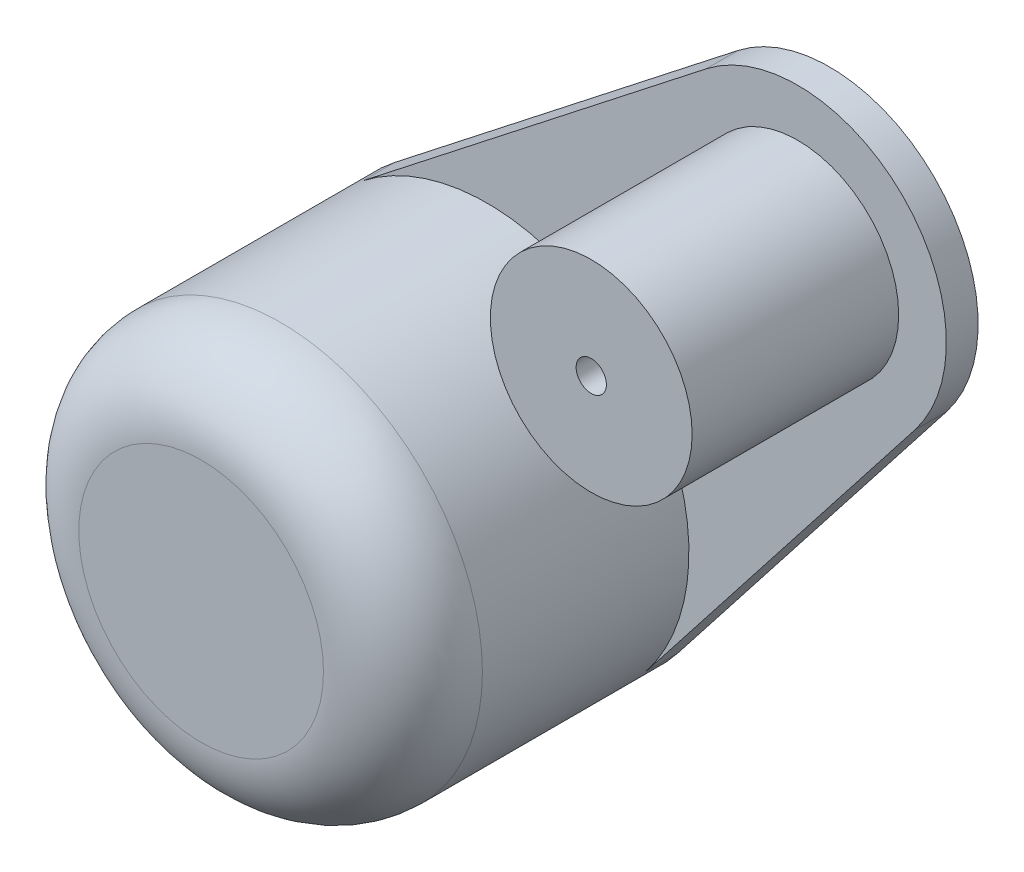
from build123d import *

# Parameters (mm, degrees)
SKETCH1_R           = 12.7
BOSS_EXTRUDE1_DEPTH = 20
FILLET1_R           = 5
CUT_EXTRUDE1_REACH  = 14.7
SKETCH3_R           = 2.4257
CUT_EXTRUDE2_REACH  = 14.7
SKETCH4_R           = 2.4257
BOSS_EXTRUDE2_DEPTH = 2
SKETCH6_R           = 6.35
BOSS_EXTRUDE3_DEPTH = 13
SKETCH8_R           = 0.9525
CUT_EXTRUDE3_DEPTH  = 16.0000001


with BuildPart() as part:
    # Sketch1 → Boss-Extrude1 (new body)
    with BuildSketch(Plane.XY):
        Circle(SKETCH1_R)
    extrude(amount=BOSS_EXTRUDE1_DEPTH)

    # Sketch2 → Cut-Revolve1 (revolve, cut)
    with BuildSketch(Plane(origin=(0, 0, 0), x_dir=(1, 0, 0), z_dir=(0, 1, 0))):
        Polygon((0, 0), (0, -17.175), (3.175, -14), (3.175, 0), align=None)
    revolve(axis=Axis((0, 0, -1), (0, 0, 1)), mode=Mode.SUBTRACT)

    # Fillet1
    fillet1_edges = [part.edges().sort_by_distance(p)[0] for p in [
        (-12.7, 0, 20),
    ]]
    fillet(fillet1_edges, radius=FILLET1_R)

    # Sketch3 → Cut-Extrude1 (cut, up to next)
    with BuildSketch(Plane(origin=(0, 0, 0), x_dir=(1, 0, 0), z_dir=(0, 1, 0)), mode=Mode.PRIVATE) as cut_extrude1_sk1:
        with Locations((0, -6)):
            Circle(SKETCH3_R)
    cut_extrude1_tool1 = extrude(cut_extrude1_sk1.sketch, amount=-CUT_EXTRUDE1_REACH, mode=Mode.PRIVATE) & part.part
    add(cut_extrude1_tool1.solids().sort_by_distance((0, 0, 6))[0], mode=Mode.SUBTRACT)

    # Sketch4 → Cut-Extrude2 (cut, up to next)
    with BuildSketch(Plane(origin=(0, 0, 0), x_dir=(0, 0, -1), z_dir=(1, 0, 0)), mode=Mode.PRIVATE) as cut_extrude2_sk1:
        with Locations((-6, 0)):
            Circle(SKETCH4_R)
    cut_extrude2_tool1 = extrude(cut_extrude2_sk1.sketch, amount=-CUT_EXTRUDE2_REACH, mode=Mode.PRIVATE) & part.part
    add(cut_extrude2_tool1.solids().sort_by_distance((0, 0, 6))[0], mode=Mode.SUBTRACT)

    # Sketch5 → Boss-Extrude2 (add)
    with BuildSketch(Plane.XY):
        with BuildLine():
            Line((13.789783932, 26.915271857), (-7.826077627, 10.002125223))
            ThreePointArc((-7.826077627, 10.002125223), (8.980256121, 8.980256121), (10.002125223, -7.826077627))
            Line((10.002125223, -7.826077627), (26.915271857, 13.789783932))
            ThreePointArc((26.915271857, 13.789783932), (26.162950904, 26.162950904), (13.789783932, 26.915271857))
        make_face()
    extrude(amount=BOSS_EXTRUDE2_DEPTH)

    # Sketch6 → Boss-Extrude3 (add)
    with BuildSketch(Plane.XY.offset(2)):
        with Locations((19.5515025, 19.5515025)):
            Circle(SKETCH6_R)
    extrude(amount=BOSS_EXTRUDE3_DEPTH)

    # Sketch7 → Cut-Revolve2 (revolve, cut)
    with BuildSketch(Plane(origin=(0, 0, 0), x_dir=(0, 0, 1), z_dir=(-0.707106781, 0.707106781, 0))):
        Polygon((0, 30.65), (4, 30.65), (7, 27.65), (0, 27.65), align=None)
    revolve(axis=Axis((19.5515025, 19.5515025, 15), (0, 0, -1)), mode=Mode.SUBTRACT)

    # Sketch8 → Cut-Extrude3 (cut, through all)
    with BuildSketch(Plane.XY.offset(15)):
        with Locations((19.5515025, 19.5515025)):
            Circle(SKETCH8_R)
    extrude(amount=-CUT_EXTRUDE3_DEPTH, mode=Mode.SUBTRACT)


solid = part.part
